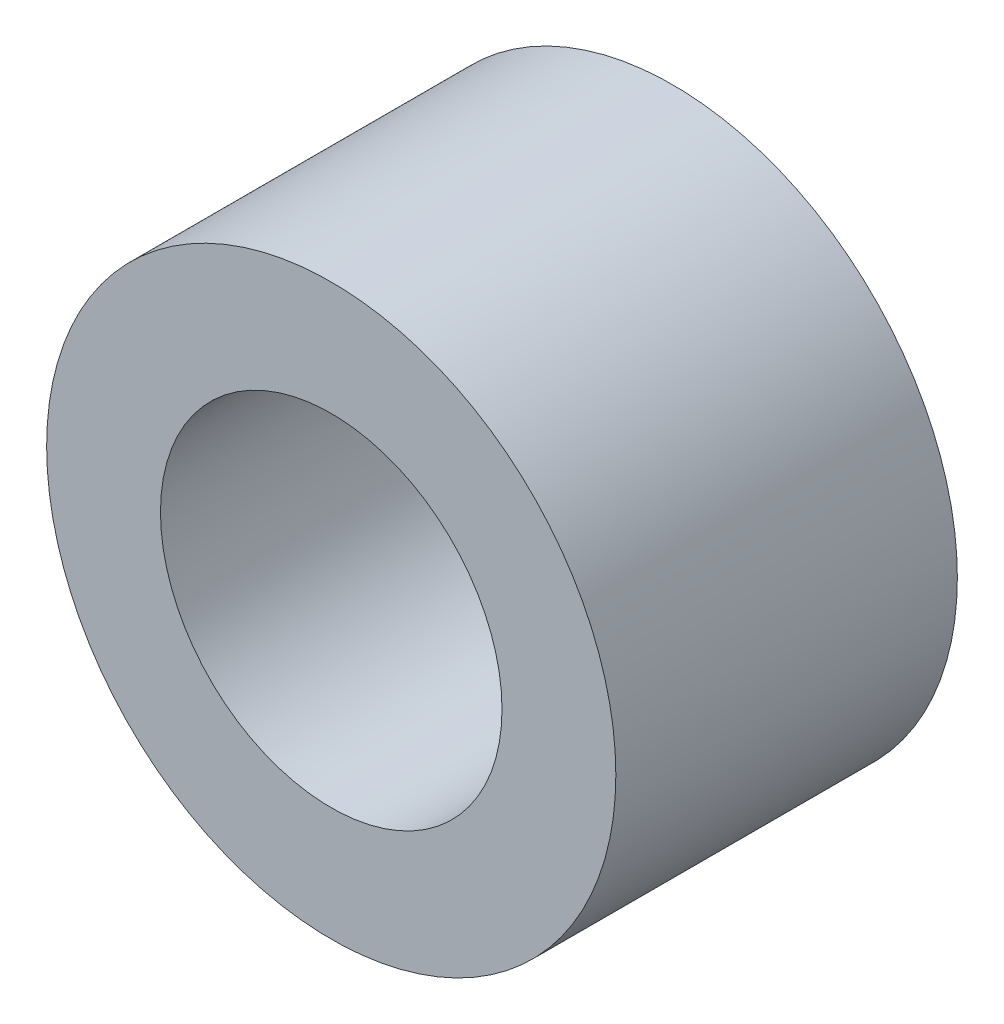
from build123d import *

# Parameters (mm, degrees)
SKETCH1_R               = 25
BOSS_EXTRUDE1_DEPTH     = 15
SKETCH2_R               = 15
CUT_EXTRUDE1_DEPTH      = 110
CUT_EXTRUDE1_DEPTH_BACK = 112


with BuildPart() as part:
    # Sketch1 → Boss-Extrude1 (new body, symmetric)
    with BuildSketch(Plane.XY):
        Circle(SKETCH1_R)
    extrude(amount=BOSS_EXTRUDE1_DEPTH, both=True)

    # Sketch2 → Cut-Extrude1 (cut, two sides)
    with BuildSketch(Plane.XY.offset(15)) as cut_extrude1_sk:
        Circle(SKETCH2_R)
    extrude(amount=CUT_EXTRUDE1_DEPTH, mode=Mode.SUBTRACT)
    extrude(cut_extrude1_sk.sketch, amount=-CUT_EXTRUDE1_DEPTH_BACK, mode=Mode.SUBTRACT)


solid = part.part
